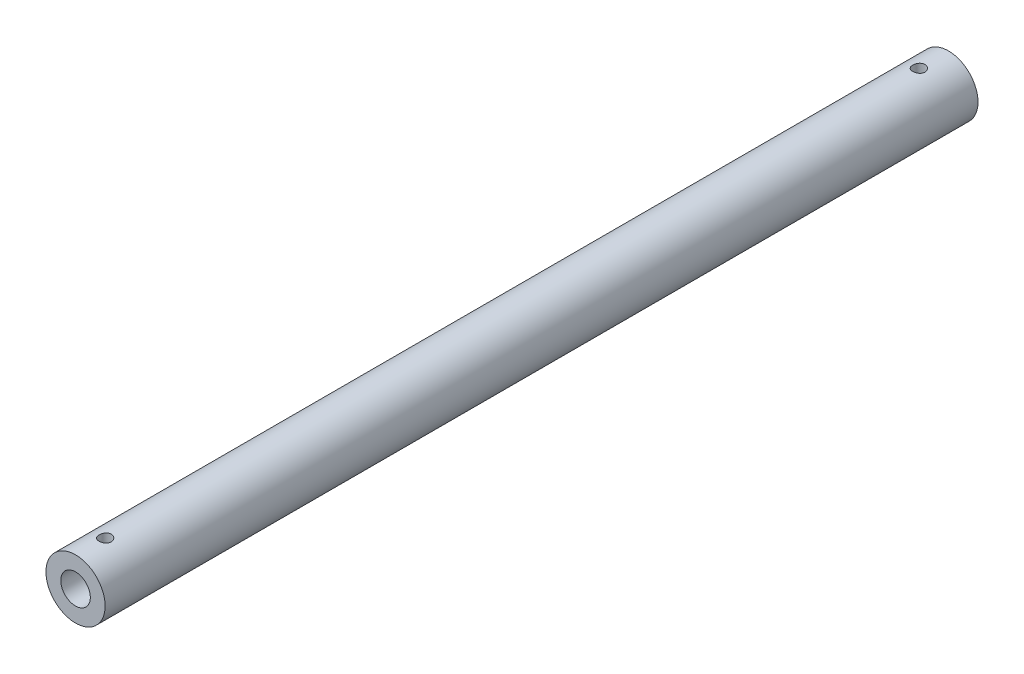
from build123d import *

# Parameters (mm, degrees)
BOSS_EXTRUDE1_DEPTH      = 221.25
BOSS_EXTRUDE1_DEPTH_BACK = 221.25
SKETCH1_R                = 15
SKETCH1_R_2              = 7.5
SKETCH3_R                = 3.1
CUT_EXTRUDE1_DEPTH       = 223.264622691


with BuildPart() as part:
    # Sketch1 → Boss-Extrude1 (new, two sides: drawn at the far end of the back side and taken through both)
    with BuildSketch(Plane.XY.offset(-BOSS_EXTRUDE1_DEPTH_BACK)):
        Circle(SKETCH1_R)
        Circle(SKETCH1_R_2, mode=Mode.SUBTRACT)
    extrude(amount=BOSS_EXTRUDE1_DEPTH + BOSS_EXTRUDE1_DEPTH_BACK)

    # Sketch3 → Cut-Extrude1 (cut, through all)
    with BuildSketch(Plane(origin=(0, 0, 0), x_dir=(1, 0, 0), z_dir=(0, 1, 0))):
        with Locations((0, 206.25)):
            Circle(SKETCH3_R)
    cut_extrude1 = extrude(amount=CUT_EXTRUDE1_DEPTH, mode=Mode.SUBTRACT)

    # Mirror1: Cut-Extrude1 across plane
    add(cut_extrude1.mirror(Plane.XY), mode=Mode.SUBTRACT)


solid = part.part
